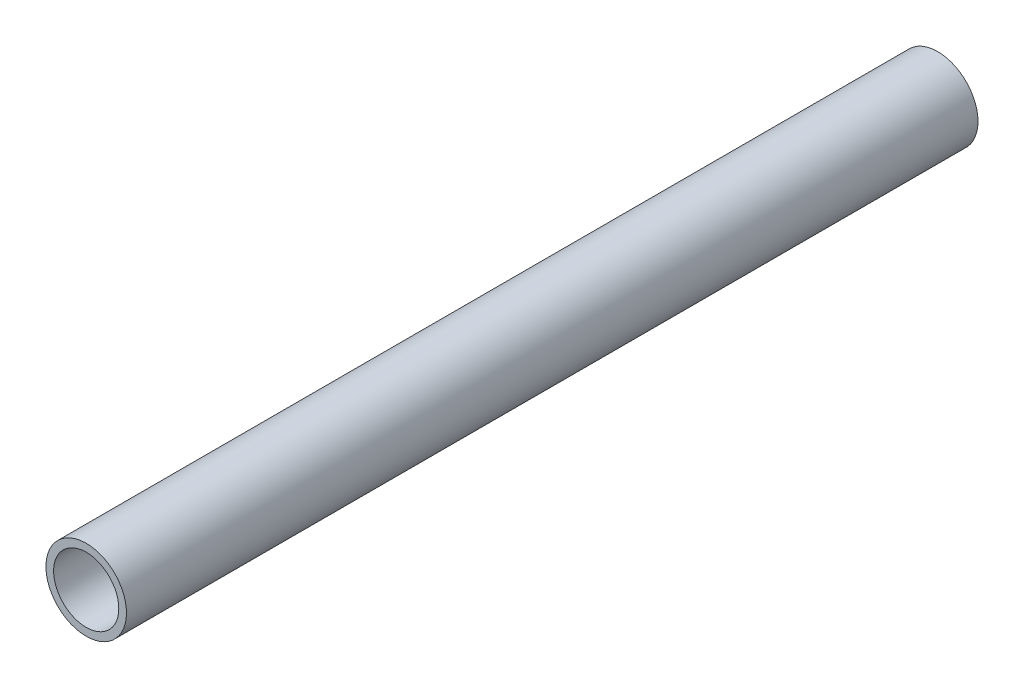
from build123d import *

# Parameters (mm, degrees)
SKETCH1_R           = 175
SKETCH1_R_2         = 141.5
BOSS_EXTRUDE1_DEPTH = 1850


with BuildPart() as part:
    # Sketch1 → Boss-Extrude1 (new body, symmetric)
    with BuildSketch(Plane.XY):
        Circle(SKETCH1_R)
        Circle(SKETCH1_R_2, mode=Mode.SUBTRACT)
    extrude(amount=BOSS_EXTRUDE1_DEPTH, both=True)


solid = part.part
